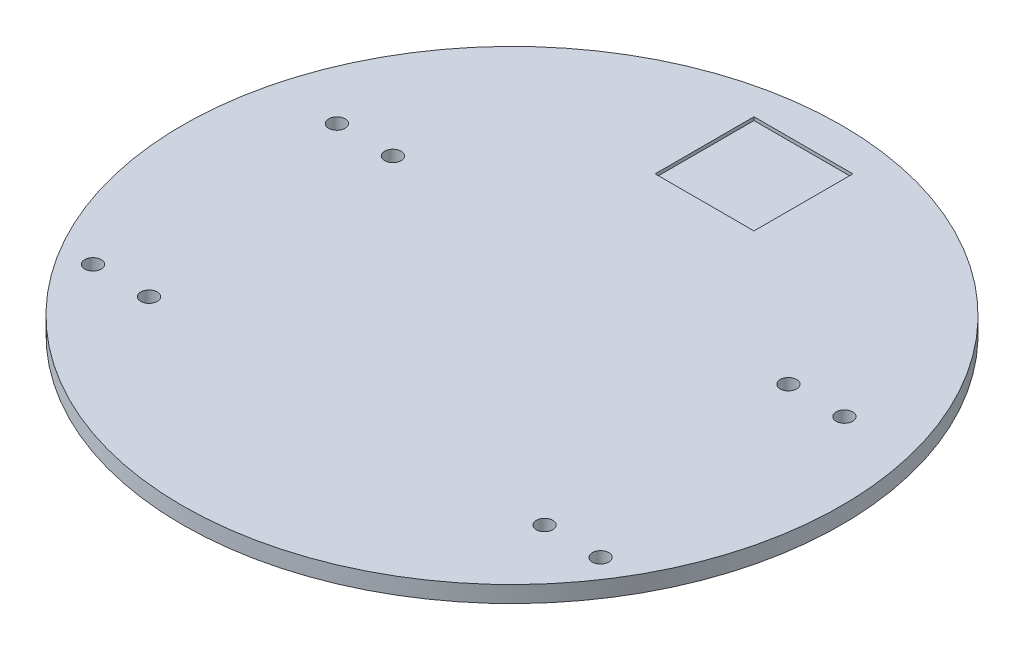
from build123d import *

# Parameters (mm, degrees)
SKETCH1_R           = 100
BOSS_EXTRUDE1_DEPTH = 5
SKETCH2_R           = 2.5
CUT_EXTRUDE1_DEPTH  = 10
SKETCH3_W           = 30
SKETCH3_H           = 30
CUT_EXTRUDE2_DEPTH  = 1


with BuildPart() as part:
    # Sketch1 → Boss-Extrude1 (new body)
    with BuildSketch(Plane(origin=(0, 0, 0), x_dir=(1, 0, 0), z_dir=(0, 1, 0))):
        Circle(SKETCH1_R)
    extrude(amount=BOSS_EXTRUDE1_DEPTH)

    # Sketch2 → Cut-Extrude1 (cut)
    with BuildSketch(Plane(origin=(0, 5, 0), x_dir=(1, 0, 0), z_dir=(0, 1, 0))):
        with Locations((-77, -50.128296411)):
            Circle(SKETCH2_R)
        with Locations((-77, 23.871703589)):
            Circle(SKETCH2_R)
        with Locations((-60, -50.128296411)):
            Circle(SKETCH2_R)
        with Locations((-60, 23.871703589)):
            Circle(SKETCH2_R)
        with Locations((60, 23.871703589)):
            Circle(SKETCH2_R)
        with Locations((60, -50.128296411)):
            Circle(SKETCH2_R)
        with Locations((77, 23.871703589)):
            Circle(SKETCH2_R)
        with Locations((77, -50.128296411)):
            Circle(SKETCH2_R)
    extrude(amount=-CUT_EXTRUDE1_DEPTH, mode=Mode.SUBTRACT)

    # Sketch3 → Cut-Extrude2 (cut)
    with BuildSketch(Plane(origin=(0, 5, 0), x_dir=(1, 0, 0), z_dir=(0, 1, 0))):
        with Locations((-0.508280415, 73.936051257)):
            Rectangle(SKETCH3_W, SKETCH3_H)
    extrude(amount=-CUT_EXTRUDE2_DEPTH, mode=Mode.SUBTRACT)


solid = part.part
